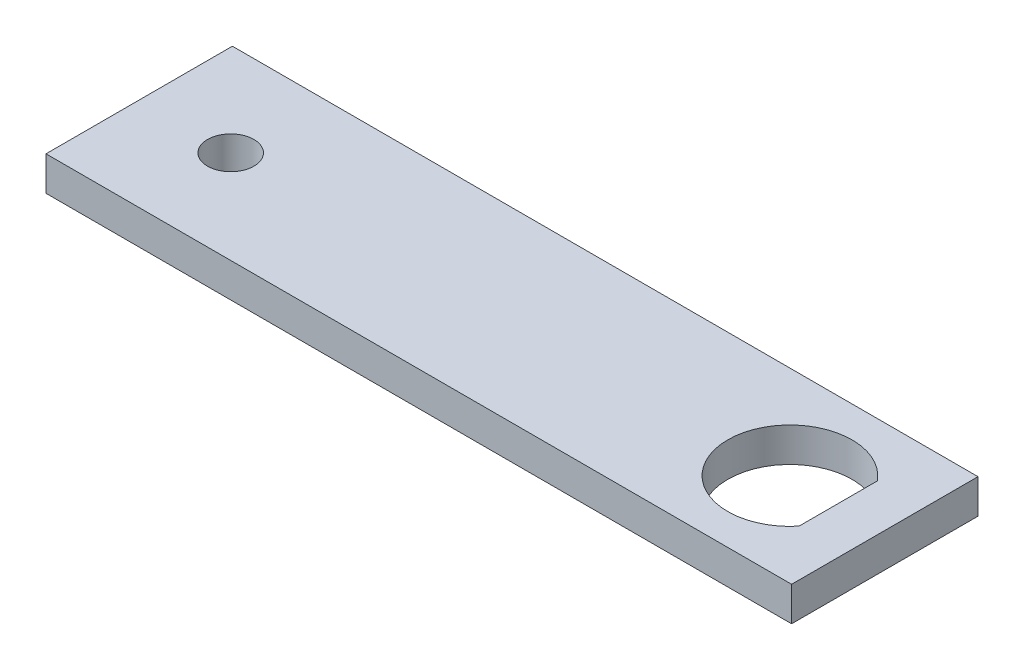
from build123d import *

# Parameters (mm, degrees)
SKETCH1_W           = 76.2
SKETCH1_H           = 19.05
SKETCH1_R           = 2.37
BOSS_EXTRUDE1_DEPTH = 3.5


with BuildPart() as part:
    # Sketch1 → Boss-Extrude1 (new body)
    with BuildSketch(Plane(origin=(0, 0, 0), x_dir=(1, 0, 0), z_dir=(0, 1, 0))):
        with Locations((38.1, 9.525)):
            Rectangle(SKETCH1_W, SKETCH1_H)
        with Locations((9.35, 9.525)):
            Circle(SKETCH1_R, mode=Mode.SUBTRACT)
        with BuildLine():
            Line((71.433, 13.523501094), (71.433, 5.526498906))
            ThreePointArc((71.433, 5.526498906), (60.15, 9.525), (71.433, 13.523501094))
        make_face(mode=Mode.SUBTRACT)
    extrude(amount=BOSS_EXTRUDE1_DEPTH)


solid = part.part
